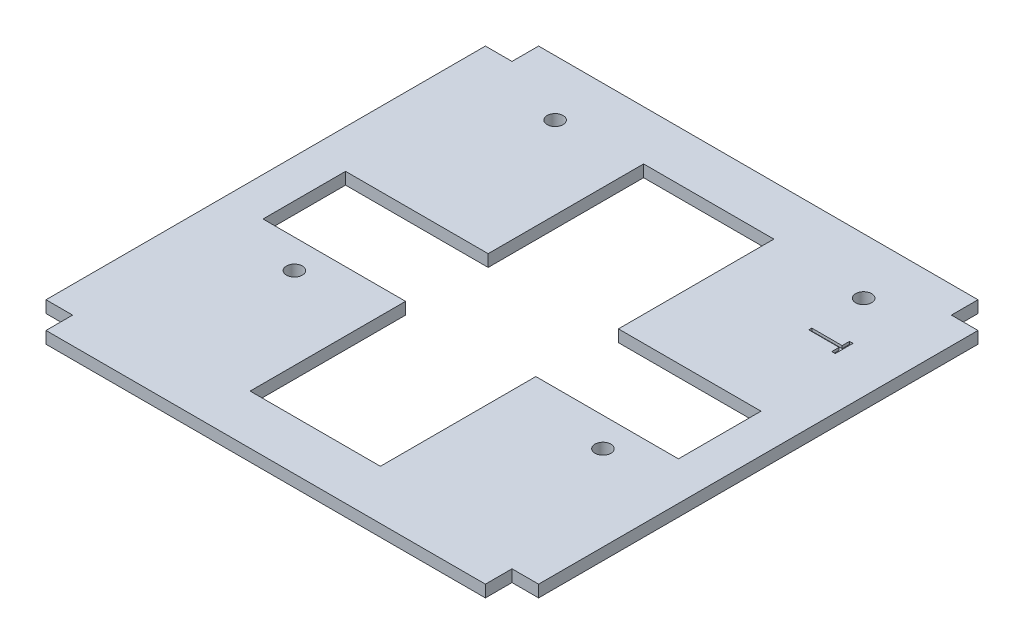
from build123d import *

# Parameters (mm, degrees)
SKETCH2_W           = 5
SKETCH2_H           = 82.6
SKETCH2_W_2         = 82.6
SKETCH2_H_2         = 5
BOSS_EXTRUDE1_DEPTH = 2.25
SKETCH5_R           = 1.5
CUT_EXTRUDE3_DEPTH  = 10
SKETCH6_W           = 24.487512306
SKETCH6_H           = 29.223395674
SKETCH6_H_2         = 15.523504638
SKETCH6_W_2         = 26.803129216
CUT_EXTRUDE4_DEPTH  = 10
CUT_EXTRUDE5_DEPTH  = 0.5


with BuildPart() as part:
    # Sketch2 → Boss-Extrude1 (new body)
    with BuildSketch(Plane(origin=(0, 0, 0), x_dir=(1, 0, 0), z_dir=(0, 1, 0))):
        with Locations((-43.8, 0)):
            Rectangle(SKETCH2_W, SKETCH2_H)
        Rectangle(SKETCH2_W_2, SKETCH2_H)
        with Locations((0, -43.8)):
            Rectangle(SKETCH2_W_2, SKETCH2_H_2)
        with Locations((43.8, 0)):
            Rectangle(SKETCH2_W, SKETCH2_H)
        with Locations((0, 43.8)):
            Rectangle(SKETCH2_W_2, SKETCH2_H_2)
    extrude(amount=BOSS_EXTRUDE1_DEPTH)

    # Sketch5 → Cut-Extrude3 (cut)
    with BuildSketch(Plane(origin=(0, 2.25, 0), x_dir=(1, 0, 0), z_dir=(0, 1, 0))):
        with Locations((-27.7, 35.8)):
            Circle(SKETCH5_R)
        with Locations((30.3, 35.8)):
            Circle(SKETCH5_R)
        with Locations((30.3, -13.2)):
            Circle(SKETCH5_R)
        with Locations((-27.7, -13.2)):
            Circle(SKETCH5_R)
    extrude(amount=-CUT_EXTRUDE3_DEPTH, mode=Mode.SUBTRACT)

    # Sketch6 → Cut-Extrude4 (cut)
    with BuildSketch(Plane(origin=(0, 2.25, 0), x_dir=(1, 0, 0), z_dir=(0, 1, 0))):
        with Locations((0, 22.373450156)):
            Rectangle(SKETCH6_W, SKETCH6_H)
        Rectangle(SKETCH6_W, SKETCH6_H_2)
        with Locations((25.645320761, 0)):
            Rectangle(SKETCH6_W_2, SKETCH6_H_2)
        with Locations((0, -22.373450156)):
            Rectangle(SKETCH6_W, SKETCH6_H)
        with Locations((-25.645320761, 0)):
            Rectangle(SKETCH6_W_2, SKETCH6_H_2)
    extrude(amount=-CUT_EXTRUDE4_DEPTH, mode=Mode.SUBTRACT)

    # Sketch7 → Cut-Extrude5 (cut)
    with BuildSketch(Plane(origin=(0, 2.25, 0), x_dir=(1, 0, 0), z_dir=(0, 1, 0))):
        Polygon((35.998717949, 27.449358974), (36.65, 27.449358974), (36.65, 24.111538462), (35.998717949, 24.111538462), (35.998717949, 25.495512821), (30.3, 25.495512821), (30.3, 26.065384615), (35.998717949, 26.065384615), align=None)
    extrude(amount=-CUT_EXTRUDE5_DEPTH, mode=Mode.SUBTRACT)


solid = part.part
